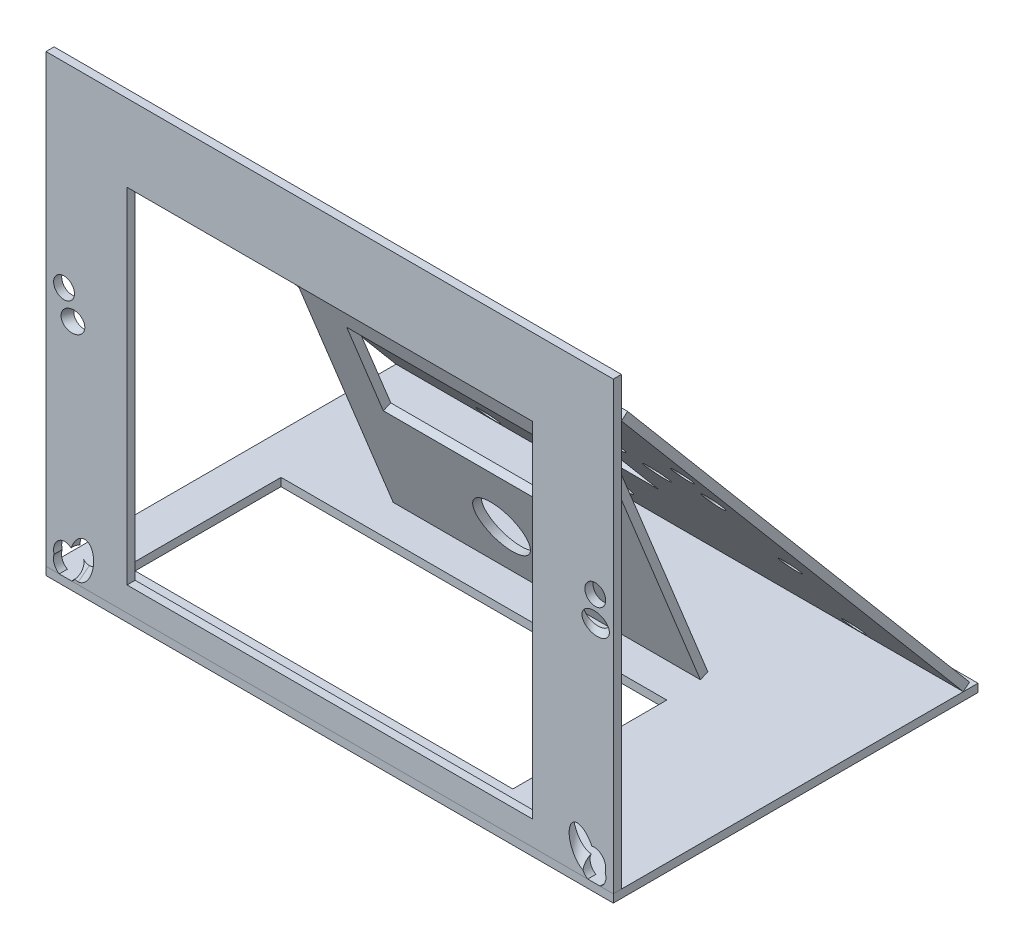
from build123d import *

# Parameters (mm, degrees)
BOSS_EXTRUDE1_DEPTH     = 10
SKETCH3_W               = 700
SKETCH3_H               = 550
BOSS_EXTRUDE3_DEPTH     = 10
SKETCH4_R               = 22.86
SKETCH4_R_2             = 12.7
SKETCH4_RX              = 13.0679054
SKETCH4_RY              = 12.7
SKETCH4_RX_2            = 16.82158831
BOSS_EXTRUDE4_DEPTH     = 10
SKETCH5_RX              = 12.859275416
SKETCH5_RY              = 12.7
SKETCH5_W               = 500
SKETCH5_H               = 425
CUT_EXTRUDE1_DEPTH      = 787.511284134
CUT_EXTRUDE5_DEPTH      = 773.607828861
CUT_EXTRUDE5_DEPTH_BACK = 773.607828861
CUT_EXTRUDE6_DEPTH      = 786.851226243
CUT_EXTRUDE6_DEPTH_BACK = 786.851226243
SKETCH13_R              = 12.7
CUT_EXTRUDE7_DEPTH      = 763.694640177
CUT_EXTRUDE7_DEPTH_BACK = 763.694640177
SKETCH14_R              = 12.7
CUT_EXTRUDE8_DEPTH      = 775.162192864
CUT_EXTRUDE8_DEPTH_BACK = 775.162192864
SKETCH7_W               = 379
SKETCH7_H               = 336.704567283
BOSS_EXTRUDE5_DEPTH     = 10
CUT_EXTRUDE2_DEPTH      = 787.511284204
SKETCH9_W               = 476
SKETCH9_H               = 190
CUT_EXTRUDE3_DEPTH      = 10
SKETCH10_W              = 279
SKETCH10_H              = 120.581494641
CUT_EXTRUDE4_DEPTH      = 625.0537399


with BuildPart() as part:
    # Sketch1 → Boss-Extrude1 (new body)
    with BuildSketch(Plane(origin=(0, 0, 0), x_dir=(1, 0, 0), z_dir=(0, 1, 0))):
        Polygon((-350, 0), (-350, -10), (350, -10), (350, 0), (350, 440), (-350, 440), align=None)
    extrude(amount=-BOSS_EXTRUDE1_DEPTH)

    # Sketch9 → Cut-Extrude3 (cut)
    with BuildSketch(Plane(origin=(0, 0, 0), x_dir=(1, 0, 0), z_dir=(0, 1, 0))):
        with Locations((-62, 135)):
            Rectangle(SKETCH9_W, SKETCH9_H)
    extrude(amount=-CUT_EXTRUDE3_DEPTH, mode=Mode.SUBTRACT)


with BuildPart() as body_2:
    # Sketch3 → Boss-Extrude3 (new body)
    with BuildSketch(Plane.XY):
        with Locations((0, 275)):
            Rectangle(SKETCH3_W, SKETCH3_H)
    extrude(amount=BOSS_EXTRUDE3_DEPTH)

    # Sketch5 → Cut-Extrude1 (cut, through all)
    with BuildSketch(Plane(origin=(0, 0, 0), x_dir=(-1, 0, 0), z_dir=(0, 0, -1))):
        with Locations((327.765352448, 308.7)):
            Ellipse(SKETCH5_RX, SKETCH5_RY)
        with Locations(Location((-327.765352448, 308.7), (0, 0, 180))):
            Ellipse(SKETCH5_RX, SKETCH5_RY)
        with Locations((0, 242.5)):
            Rectangle(SKETCH5_W, SKETCH5_H)
        with BuildLine():
            Line((340.076614938, 17.492780847), (339.954014401, 17.850745349))
            add(Edge.make_bspline(
                [(339.954014401, 17.850745349), (345.143360832, 34.782508497), (328.928082109, 37.833579814), (312.712803386, 40.884651131), (315.037863876, 22.538975104)],
                knots=[0.92699498, 0.92699498, 0.92699498, 2.731624005, 2.731624005, 4.536253029, 4.536253029, 4.536253029], degree=2, weights=[1, 0.619795285, 1, 0.619795285, 1]))
            ThreePointArc((315.037863876, 22.538975104), (323.160520615, -1.800235661), (340.076614938, 17.492780847))
        make_face()
        with BuildLine():
            Line((-340.076614938, 17.492780847), (-339.954014401, 17.850745349))
            add(Edge.make_bspline(
                [(-315.037863876, 22.538975104), (-312.712803386, 40.884651131), (-328.928082109, 37.833579814), (-345.143360832, 34.782508497), (-339.954014401, 17.850745349)],
                knots=[1.746932278, 1.746932278, 1.746932278, 3.551561302, 3.551561302, 5.356190327, 5.356190327, 5.356190327], degree=2, weights=[1, 0.619795285, 1, 0.619795285, 1]))
            ThreePointArc((-315.037863876, 22.538975104), (-323.160520615, -1.800235661), (-340.076614938, 17.492780847))
        make_face()
    extrude(amount=-CUT_EXTRUDE1_DEPTH, mode=Mode.SUBTRACT)


with BuildPart() as body_3:
    # Sketch4 → Boss-Extrude4 (new body)
    with BuildSketch(Plane(origin=(0, 207.911938093, -246.537662204), x_dir=(0.6591701496284476, 0.5748622268654293, 0.48479700283946675), z_dir=(-1.5626389071599078e-14, -0.6446821586740011, 0.7644507271809153))):
        Polygon((-435.233517314, 83.91964816), (26.185587426, -442.476029805), (518.285061134, -11.119717233), (56.865956394, 515.275960733), align=None)
        with Locations(Location((112.918455099, 151.270623589, 0), (0, 0, 221.236614357))):
            Circle(SKETCH4_R, mode=Mode.SUBTRACT)
        with Locations(Location((218.264919068, 31.089376752, 0), (0, 0, 221.236614357))):
            Circle(SKETCH4_R, mode=Mode.SUBTRACT)
        with Locations(Location((164.268996262, 92.688950981, 0), (0, 0, 221.236614357))):
            Circle(SKETCH4_R, mode=Mode.SUBTRACT)
        with Locations(Location((60.228480193, 211.380347651, 0), (0, 0, 221.236614357))):
            Circle(SKETCH4_R, mode=Mode.SUBTRACT)
        with Locations(Location((-340.531356596, 1.084882942, 0), (0, 0, 221.236614357))):
            Circle(SKETCH4_R_2, mode=Mode.SUBTRACT)
        with Locations(Location((-43.530472171, -337.739366656, 0), (0, 0, 221.236614357))):
            Circle(SKETCH4_R_2, mode=Mode.SUBTRACT)
        with Locations(Location((-219.330148511, 185.730424894), (0, 0, 76.974673236))):
            Ellipse(SKETCH4_RX, SKETCH4_RY, mode=Mode.SUBTRACT)
        with Locations(Location((155.400197312, -241.769070505), (0, 0, 5.498555478))):
            Ellipse(SKETCH4_RX, SKETCH4_RY, mode=Mode.SUBTRACT)
        with Locations(Location((-99.990435592, 314.085756385), (0, 0, 55.080357381))):
            Ellipse(SKETCH4_RX_2, SKETCH4_RY, mode=Mode.SUBTRACT)
        with Locations(Location((298.281829818, -140.270807988), (0, 0, 27.392871333))):
            Ellipse(SKETCH4_RX_2, SKETCH4_RY, mode=Mode.SUBTRACT)
        with BuildLine():
            add(Edge.make_bspline(
                [(-63.589406525, 365.638126242), (-63.741643722, 366.490839487), (-63.811807912, 367.344040438), (-63.802226331, 368.62452421), (-63.779747479, 369.051466732), (-63.695955513, 369.905582542), (-63.63419469, 370.334868261), (-63.392229564, 371.605696758), (-63.1573121, 372.427821226), (-62.697837877, 373.62449563), (-62.526708317, 374.017260186), (-62.147577825, 374.790218958), (-61.938834919, 375.171261438), (-61.269012129, 376.27254411), (-60.761519114, 376.958836031), (-59.908382923, 377.916051938), (-59.608588108, 378.223008342), (-58.976762939, 378.811587105), (-58.646222903, 379.091515993), (-57.626860408, 379.875033806), (-56.904684374, 380.328514328), (-55.75539772, 380.902009401), (-55.359954245, 381.075742506), (-54.551050417, 381.38307547), (-54.142314712, 381.515025154), (-52.903487059, 381.846894035), (-52.060906133, 381.983500004), (-50.770616226, 382.054479548), (-50.335109488, 382.055278578), (-49.476888397, 382.010918539), (-48.626096803, 381.921161807), (-47.790012946, 381.741535926), (-46.961434889, 381.516047116), (-46.548362066, 381.379279156), (-45.343698182, 380.906056573), (-44.58604217, 380.508882961), (-43.515834927, 379.794005091), (-43.168650266, 379.534351406), (-42.50482651, 378.98018511), (-42.190149922, 378.687638265), (-41.295646345, 377.76556228), (-40.764177325, 377.090914101), (-39.83584308, 375.627904463), (-39.452443607, 374.861332462), (-38.990155592, 373.662494814), (-38.855012741, 373.254653305), (-38.622936719, 372.422380653), (-38.526738277, 371.999835305), (-38.299797944, 370.732150549), (-38.228045333, 369.87971787), (-38.236976836, 368.590357394), (-38.259793647, 368.156656129), (-38.344170953, 367.298648066), (-38.405488687, 366.874124363), (-38.645124385, 365.613594958), (-38.878628471, 364.790514702), (-39.341922847, 363.58236963), (-39.515380323, 363.184625552), (-39.893476553, 362.413782099), (-40.098843808, 362.038647392), (-40.763402062, 360.943788562), (-41.270570868, 360.254307986), (-42.421373772, 358.961369821), (-43.049198834, 358.37622604), (-44.062623724, 357.594981134), (-44.412767414, 357.350410692), (-45.13855202, 356.894020405), (-45.516093847, 356.681271101), (-46.675741268, 356.101984763), (-47.474523065, 355.7978672), (-48.711255059, 355.464909567), (-49.129970593, 355.374603898), (-49.980943098, 355.237265097), (-50.413921489, 355.190528534), (-51.701001558, 355.120186176), (-52.553992047, 355.163548624), (-53.825755349, 355.366261948), (-54.251017844, 355.457744441), (-55.084075609, 355.685216961), (-55.491285126, 355.82066293), (-56.287575975, 356.133784949), (-56.676656158, 356.311463676), (-57.436629623, 356.709187997), (-57.808898233, 356.93016628), (-58.888231004, 357.652553942), (-59.5448695, 358.202947844), (-60.739065941, 359.433955399), (-61.279307345, 360.121603446), (-62.197903534, 361.570266349), (-62.582601468, 362.335966672), (-63.049251357, 363.545736862), (-63.185543234, 363.957841306), (-63.417257256, 364.789995369), (-63.513287926, 365.211769619), (-63.589406525, 365.638126242)],
                knots=[0, 0, 0, 0, 0.03125, 0.03125, 0.046875, 0.046875, 0.0625, 0.0625, 0.09375, 0.09375, 0.109375, 0.109375, 0.125, 0.125, 0.15625, 0.15625, 0.171875, 0.171875, 0.1875, 0.1875, 0.21875, 0.21875, 0.234375, 0.234375, 0.25, 0.25, 0.28125, 0.28125, 0.296875, 0.296875, 0.3125, 0.328125, 0.328125, 0.34375, 0.34375, 0.375, 0.375, 0.390625, 0.390625, 0.40625, 0.40625, 0.4375, 0.4375, 0.46875, 0.46875, 0.484375, 0.484375, 0.5, 0.5, 0.53125, 0.53125, 0.546875, 0.546875, 0.5625, 0.5625, 0.59375, 0.59375, 0.609375, 0.609375, 0.625, 0.625, 0.65625, 0.65625, 0.6875, 0.6875, 0.703125, 0.703125, 0.71875, 0.71875, 0.75, 0.75, 0.765625, 0.765625, 0.78125, 0.78125, 0.8125, 0.8125, 0.828125, 0.828125, 0.84375, 0.84375, 0.859375, 0.859375, 0.875, 0.875, 0.90625, 0.90625, 0.9375, 0.9375, 0.96875, 0.96875, 0.984375, 0.984375, 1, 1, 1, 1], degree=3))
        make_face(mode=Mode.SUBTRACT)
        with BuildLine():
            add(Edge.make_bspline(
                [(345.298303979, -100.361990014), (345.211272197, -99.499040561), (345.218977587, -98.642845987), (345.364875096, -97.368132695), (345.436079438, -96.944837665), (345.624448503, -96.101524637), (345.741332728, -95.68393582), (346.15182904, -94.463880144), (346.506498991, -93.685312107), (347.157204072, -92.568457074), (347.39472286, -92.204213363), (347.899222438, -91.507881655), (348.167260863, -91.173774974), (348.733867196, -90.532746935), (349.032437938, -90.225828102), (349.659961766, -89.639044742), (349.990659854, -89.35790226), (351.014604181, -88.5670129), (351.737598777, -88.109404854), (352.879825674, -87.522616881), (353.270259965, -87.343744818), (354.070858379, -87.020045318), (354.479155436, -86.876166981), (355.710623572, -86.503035936), (356.546859009, -86.329041243), (357.824031493, -86.17986631), (358.254803607, -86.148874158), (359.118953854, -86.126040711), (359.548374856, -86.134189244), (360.828863936, -86.215941463), (361.672229711, -86.346323819), (362.921295916, -86.659714404), (363.337233419, -86.784819762), (364.149891085, -87.07192005), (364.546649569, -87.233615852), (365.708528194, -87.772544467), (366.445543035, -88.203065744), (367.491000341, -88.962732558), (367.829727228, -89.235774617), (368.470217374, -89.807942133), (368.774148072, -90.108506368), (369.349458396, -90.738526846), (369.620840048, -91.067981291), (370.13015486, -91.756578732), (370.368912426, -92.117130218), (371.026564835, -93.236584322), (371.378493969, -94.016293517), (371.779112934, -95.235007745), (371.891280771, -95.649499103), (372.071276006, -96.495605028), (372.138127271, -96.923788576), (372.268039557, -98.20399227), (372.262911285, -99.059547697), (372.117130431, -100.346021289), (372.045057589, -100.774864222), (371.858326128, -101.613656953), (371.743444213, -102.0261787), (371.471795975, -102.837839743), (371.315027113, -103.236978227), (370.959473787, -104.021830824), (370.759838785, -104.408568297), (370.110988256, -105.524527341), (369.609257638, -106.217945552), (368.757032368, -107.185249731), (368.454578377, -107.496921542), (367.824784966, -108.086808407), (367.497883634, -108.364984169), (366.482556315, -109.151150725), (365.759813767, -109.611209264), (364.606532695, -110.204686513), (364.213433886, -110.384641878), (363.418248018, -110.706369132), (362.611656501, -110.991169877), (361.782616266, -111.203291491), (360.942227576, -111.378671768), (360.5143903, -111.448192884), (359.228142415, -111.597934591), (358.37316035, -111.619975687), (357.094385917, -111.538710273), (356.668748362, -111.492439152), (355.818753364, -111.360328205), (355.392520809, -111.273874584), (354.140708802, -110.958674467), (353.33563665, -110.674371522), (352.172680202, -110.135535251), (351.792519458, -109.937068415), (351.047919055, -109.500567118), (350.684498629, -109.262779959), (349.643659104, -108.505633693), (349.006550915, -107.938119449), (348.138864758, -106.989630074), (347.863257837, -106.655575755), (347.348714552, -105.959971263), (347.111886283, -105.601631635), (346.461478742, -104.495646383), (346.107341916, -103.717361601), (345.701516049, -102.485308581), (345.588193339, -102.065753169), (345.408657694, -101.220838125), (345.341819871, -100.79346474), (345.298303979, -100.361990014)],
                knots=[0, 0, 0, 0, 0.03125, 0.03125, 0.046875, 0.046875, 0.0625, 0.0625, 0.09375, 0.09375, 0.109375, 0.109375, 0.125, 0.125, 0.140625, 0.140625, 0.15625, 0.15625, 0.1875, 0.1875, 0.203125, 0.203125, 0.21875, 0.21875, 0.25, 0.25, 0.265625, 0.265625, 0.28125, 0.28125, 0.3125, 0.3125, 0.328125, 0.328125, 0.34375, 0.34375, 0.375, 0.375, 0.390625, 0.390625, 0.40625, 0.40625, 0.421875, 0.421875, 0.4375, 0.4375, 0.46875, 0.46875, 0.484375, 0.484375, 0.5, 0.5, 0.53125, 0.53125, 0.546875, 0.546875, 0.5625, 0.5625, 0.578125, 0.578125, 0.59375, 0.59375, 0.625, 0.625, 0.640625, 0.640625, 0.65625, 0.65625, 0.6875, 0.6875, 0.703125, 0.703125, 0.71875, 0.734375, 0.734375, 0.75, 0.75, 0.78125, 0.78125, 0.796875, 0.796875, 0.8125, 0.8125, 0.84375, 0.84375, 0.859375, 0.859375, 0.875, 0.875, 0.90625, 0.90625, 0.921875, 0.921875, 0.9375, 0.9375, 0.96875, 0.96875, 0.984375, 0.984375, 1, 1, 1, 1], degree=3))
        make_face(mode=Mode.SUBTRACT)
    extrude(amount=-BOSS_EXTRUDE4_DEPTH)


with BuildPart() as cut_extrude5_tool:
    # Sketch11 → Cut-Extrude5 (new, two sides)
    with BuildSketch(Plane(origin=(249.960769517, 192.219119475, -109.904902192), x_dir=(0.9567084958205821, 0.23427625425065113, -0.17269479065392687), z_dir=(-0.2910478552140856, 0.770093573257067, -0.5676680670985846))) as cut_extrude5_sk:
        with BuildLine():
            Line((0.44989243, 14.192871337), (0.249953167, 14.19779995))
            ThreePointArc((0.249953167, 14.19779995), (-0.349931476, -14.195687654), (0.44989243, 14.192871337))
        make_face()
    extrude(amount=CUT_EXTRUDE5_DEPTH)
    extrude(cut_extrude5_sk.sketch, amount=-CUT_EXTRUDE5_DEPTH_BACK)


with BuildPart() as body_2_1:
    add(body_2.part)

    # Cut-Extrude5: cut by cut_extrude5_tool
    add(cut_extrude5_tool.part, mode=Mode.SUBTRACT)


with BuildPart() as body_3_1:
    add(body_3.part)

    # Cut-Extrude5: cut by cut_extrude5_tool
    add(cut_extrude5_tool.part, mode=Mode.SUBTRACT)


with BuildPart() as cut_extrude6_tool:
    # Sketch12 → Cut-Extrude6 (new, two sides)
    with BuildSketch(Plane(origin=(-265.038569517, 192.8742551, -105.708346007), x_dir=(-0.9796802719208667, 0.16420232560449113, -0.1151701396853083), z_dir=(-0.20056561222965602, -0.802060618517438, 0.5625586186473086))) as cut_extrude6_sk:
        with BuildLine():
            Line((-0.421947247, 14.19372962), (-0.221998667, 14.198264563))
            ThreePointArc((-0.221998667, 14.198264563), (0.321980941, -14.196349118), (-0.421947247, 14.19372962))
        make_face()
    extrude(amount=CUT_EXTRUDE6_DEPTH)
    extrude(cut_extrude6_sk.sketch, amount=-CUT_EXTRUDE6_DEPTH_BACK)


with BuildPart() as body_2_2:
    add(body_2_1.part)

    # Cut-Extrude6: cut by cut_extrude6_tool
    add(cut_extrude6_tool.part, mode=Mode.SUBTRACT)


with BuildPart() as body_3_2:
    add(body_3_1.part)

    # Cut-Extrude6: cut by cut_extrude6_tool
    add(cut_extrude6_tool.part, mode=Mode.SUBTRACT)


with BuildPart() as cut_extrude7_tool:
    # Sketch13 → Cut-Extrude7 (new, two sides)
    with BuildSketch(Plane(origin=(249.960769517, 292.279529801, -78.922065286), x_dir=(-0.7547513371742645, -0.10438153533958297, 0.647653390413276), z_dir=(-0.6560109900250604, 0.12009265785447201, -0.7451357825898506))) as cut_extrude7_sk:
        with Locations(Location((0, 0, 0), (0, 0, 317.527947407))):
            Circle(SKETCH13_R)
    extrude(amount=CUT_EXTRUDE7_DEPTH)
    extrude(cut_extrude7_sk.sketch, amount=-CUT_EXTRUDE7_DEPTH_BACK)


with BuildPart() as body_2_3:
    add(body_2_2.part)

    # Cut-Extrude7: cut by cut_extrude7_tool
    add(cut_extrude7_tool.part, mode=Mode.SUBTRACT)


with BuildPart() as body_3_3:
    add(body_3_2.part)

    # Cut-Extrude7: cut by cut_extrude7_tool
    add(cut_extrude7_tool.part, mode=Mode.SUBTRACT)


with BuildPart() as cut_extrude8_tool:
    # Sketch14 → Cut-Extrude8 (new, two sides)
    with BuildSketch(Plane(origin=(-265.038569517, 291.840523525, -79.518437224), x_dir=(0.8681973316082595, -0.07505479464920123, 0.490510113237703), z_dir=(-0.4962190981696472, -0.13131774387402698, 0.8582087489390547))) as cut_extrude8_sk:
        with Locations(Location((0, 0, 0), (0, 0, 129.062438025))):
            Circle(SKETCH14_R)
    extrude(amount=CUT_EXTRUDE8_DEPTH)
    extrude(cut_extrude8_sk.sketch, amount=-CUT_EXTRUDE8_DEPTH_BACK)


with BuildPart() as body_2_4:
    add(body_2_3.part)

    # Cut-Extrude8: cut by cut_extrude8_tool
    add(cut_extrude8_tool.part, mode=Mode.SUBTRACT)


with BuildPart() as body_3_4:
    add(body_3_3.part)

    # Cut-Extrude8: cut by cut_extrude8_tool
    add(cut_extrude8_tool.part, mode=Mode.SUBTRACT)


with BuildPart() as body_4:
    # Sketch7 → Boss-Extrude5 (new body)
    with BuildSketch(Plane(origin=(0, 98.17068642, -242.98097535), x_dir=(-1, 0, 0), z_dir=(0, 0.37460659341591285, -0.9271838545667871))):
        with Locations((13.5, 67.595289557)):
            Rectangle(SKETCH7_W, SKETCH7_H)
    extrude(amount=-BOSS_EXTRUDE5_DEPTH)


with BuildPart() as cut_extrude2_tool:
    # Sketch8 → Cut-Extrude2 (new, through all)
    with BuildSketch(Plane.XY):
        with BuildLine():
            ThreePointArc((-41.696999994, 36.413806777), (-8.63222934, 69.478577441), (-41.697, 102.543348098))
            ThreePointArc((-41.697, 102.543348098), (-74.76177066, 69.478577434), (-41.696999994, 36.413806777))
        make_face()
    extrude(amount=-CUT_EXTRUDE2_DEPTH)


with BuildPart() as body_3_5:
    add(body_3_4.part)

    # Cut-Extrude2: cut by cut_extrude2_tool
    add(cut_extrude2_tool.part, mode=Mode.SUBTRACT)


with BuildPart() as body_4_1:
    add(body_4.part)

    # Cut-Extrude2: cut by cut_extrude2_tool
    add(cut_extrude2_tool.part, mode=Mode.SUBTRACT)


with BuildPart() as cut_extrude4_tool:
    # Sketch10 → Cut-Extrude4 (new, through all)
    with BuildSketch(Plane(origin=(0, 94.424620486, -233.709136804), x_dir=(1, 0, 0), z_dir=(0, -0.37460659341591285, 0.9271838545667872))):
        with Locations((-13.5, 125.656825878)):
            Rectangle(SKETCH10_W, SKETCH10_H)
    extrude(amount=-CUT_EXTRUDE4_DEPTH)


with BuildPart() as body_3_6:
    add(body_3_5.part)

    # Cut-Extrude4: cut by cut_extrude4_tool
    add(cut_extrude4_tool.part, mode=Mode.SUBTRACT)


with BuildPart() as body_4_2:
    add(body_4_1.part)

    # Cut-Extrude4: cut by cut_extrude4_tool
    add(cut_extrude4_tool.part, mode=Mode.SUBTRACT)


solid = Compound([part.part, body_2_4.part, body_3_6.part, body_4_2.part])
